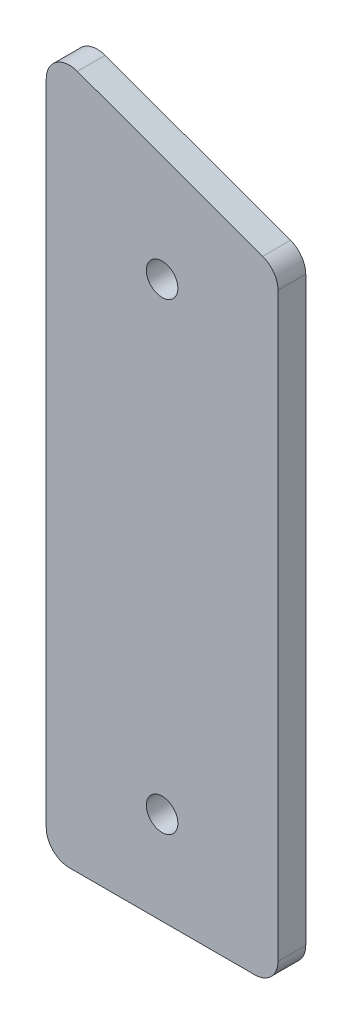
from build123d import *

# Parameters (mm, degrees)
SKETCH1_R          = 3.4
BASE_EXTRUDE_DEPTH = 6


with BuildPart() as part:
    # Sketch1 → Base-Extrude (new body)
    with BuildSketch(Plane.XY):
        with BuildLine():
            Line((-20, 0), (20, 0))
            ThreePointArc((20, 0), (23.535533906, 1.464466094), (25, 5))
            Line((25, 5), (25, 130.441190629))
            ThreePointArc((25, 130.441190629), (24.095760221, 133.309072811), (21.710100717, 135.139653733))
            Line((21.710100717, 135.139653733), (-18.289899283, 149.698463104))
            ThreePointArc((-18.289899283, 149.698463104), (-22.867882182, 149.095760221), (-25, 145))
            Line((-25, 145), (-25, 5))
            ThreePointArc((-25, 5), (-23.535533906, 1.464466094), (-20, 0))
        make_face()
        with Locations((0, 120)):
            Circle(SKETCH1_R, mode=Mode.SUBTRACT)
        with Locations((0, 20)):
            Circle(SKETCH1_R, mode=Mode.SUBTRACT)
    extrude(amount=BASE_EXTRUDE_DEPTH)


solid = part.part
